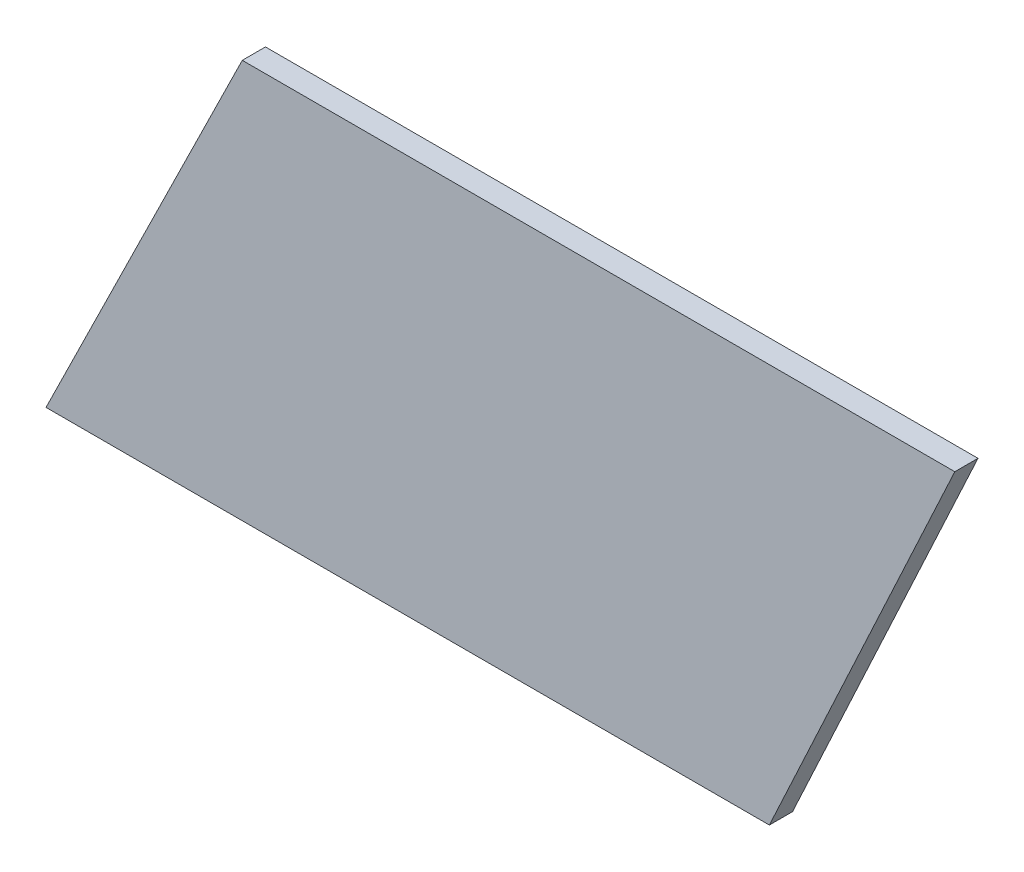
from build123d import *

# Parameters (mm, degrees)
BOSS_EXTRUDE1_DEPTH = 0.75
SKETCH2_R           = 15.265
CUT_EXTRUDE1_DEPTH  = 47.8


with BuildPart() as part:
    # Sketch1 → Boss-Extrude1 (new body, symmetric)
    with BuildSketch(Plane.XY):
        Polygon((0, 15.245), (12, 41.045), (-34.1, 41.045), (-46.8, 15.245), align=None)
    extrude(amount=BOSS_EXTRUDE1_DEPTH, both=True)

    # Sketch2 → Cut-Extrude1 (cut, through all)
    with BuildSketch(Plane(origin=(0, 0, 0), x_dir=(0, 0, -1), z_dir=(1, 0, 0))):
        Circle(SKETCH2_R)
    extrude(amount=-CUT_EXTRUDE1_DEPTH, mode=Mode.SUBTRACT)


solid = part.part
